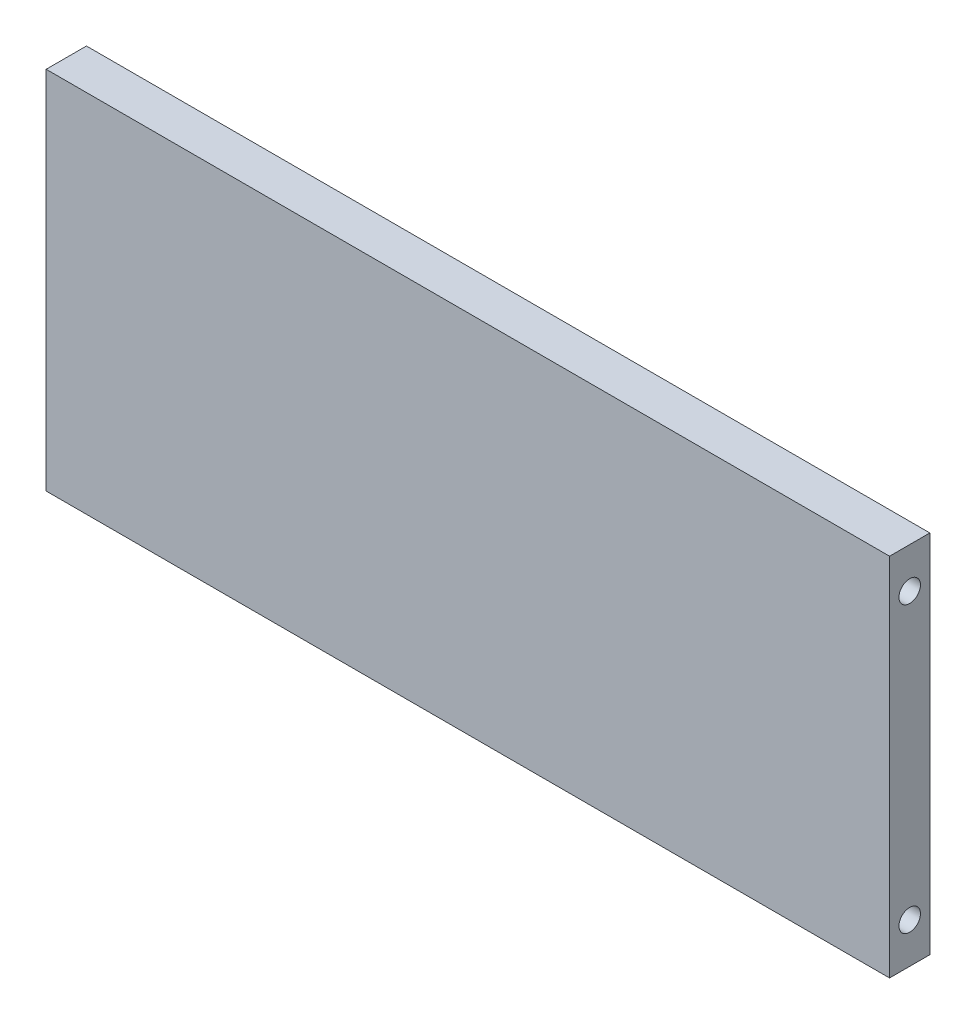
from build123d import *

# Parameters (mm, degrees)
SKETCH1_W               = 314
SKETCH1_H               = 136
BOSS_EXTRUDE1_DEPTH     = 15
SKETCH2_R               = 4
CUT_EXTRUDE1_DEPTH      = 10
LPATTERN2_COUNT         = 2
LPATTERN2_PITCH         = 106
MIRROR1_COPY_1_SKETCH_R = 4
MIRROR1_COPY_1_DEPTH    = 10
SKETCH3_R               = 4
CUT_EXTRUDE2_DEPTH      = 10
LPATTERN1_COUNT         = 3
LPATTERN1_PITCH         = 142


with BuildPart() as part:
    # Sketch1 → Boss-Extrude1 (new body)
    with BuildSketch(Plane.XY):
        Rectangle(SKETCH1_W, SKETCH1_H)
    extrude(amount=BOSS_EXTRUDE1_DEPTH)

    # Sketch2 → Cut-Extrude1 (cut)
    with BuildSketch(Plane.ZY.offset(157)):
        with Locations((7.5, 53)):
            Circle(SKETCH2_R)
    cut_extrude1 = extrude(amount=-CUT_EXTRUDE1_DEPTH, mode=Mode.SUBTRACT)

    # LPattern2: Cut-Extrude1 ×2
    with Locations(*[(0, -i * LPATTERN2_PITCH, 0) for i in range(1, LPATTERN2_COUNT)]):
        add(cut_extrude1, mode=Mode.SUBTRACT)

    # Mirror1: Cut-Extrude1 across plane
    add(cut_extrude1.mirror(Plane(origin=(0, 0, 0), x_dir=(0, 0, 1), z_dir=(1, 0, 0))), mode=Mode.SUBTRACT)

    # Mirror1 copy 1 sketch → Mirror1 copy 1 (cut)
    with BuildSketch(Plane(origin=(157, -106, 0), x_dir=(0, 0, 1), z_dir=(1, 0, 0))):
        with Locations((7.5, -53)):
            Circle(MIRROR1_COPY_1_SKETCH_R)
    extrude(amount=-MIRROR1_COPY_1_DEPTH, mode=Mode.SUBTRACT)

    # Sketch3 → Cut-Extrude2 (cut)
    with BuildSketch(Plane.XZ.offset(68)):
        with Locations((-142, 7.5)):
            Circle(SKETCH3_R)
    cut_extrude2 = extrude(amount=-CUT_EXTRUDE2_DEPTH, mode=Mode.SUBTRACT)

    # LPattern1: Cut-Extrude2 ×3
    with Locations(*[(i * LPATTERN1_PITCH, 0, 0) for i in range(1, LPATTERN1_COUNT)]):
        add(cut_extrude2, mode=Mode.SUBTRACT)


solid = part.part
